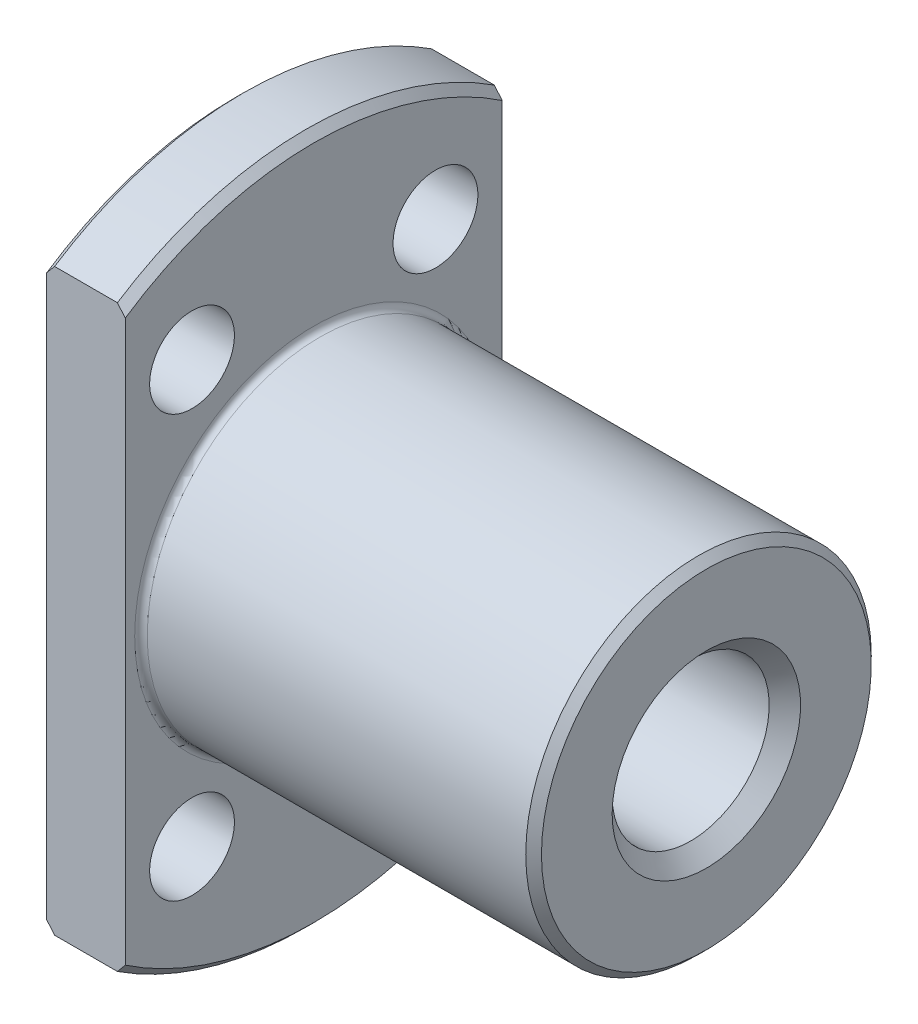
from build123d import *

# Parameters (mm, degrees)
SKETCH3_W               = 48
SKETCH3_H               = 132
SKETCH3_W_2             = 24
SKETCH3_H_2             = 88
CUT_EXTRUDE1_DEPTH      = 7.5
CUT_EXTRUDE1_DEPTH_BACK = 7.5
SKETCH4_R               = 2.7
CUT_EXTRUDE2_DEPTH      = 6
SKETCH5_R               = 2.7
CUT_EXTRUDE3_DEPTH      = 6
SKETCH6_R               = 2.7
CUT_EXTRUDE4_DEPTH      = 6
SKETCH7_R               = 2.7
CUT_EXTRUDE5_DEPTH      = 6


with BuildPart() as part:
    # Sketch1 → Revolve1 (revolve)
    with BuildSketch(Plane.XY):
        with BuildLine():
            Line((0, 0), (0, 21.5))
            Line((0, 21.5), (0.5, 22))
            Line((0.5, 22), (4.5, 22))
            Line((4.5, 22), (5, 21.5))
            Line((5, 21.5), (5, 11.4))
            ThreePointArc((5, 11.4), (5.117157288, 11.117157288), (5.4, 11))
            Line((5.4, 11), (29.5, 11))
            Line((29.5, 11), (30, 10.5))
            Line((30, 10.5), (30, 0))
            Line((30, 0), (0, 0))
        make_face()
    revolve(axis=Axis((30, 0, 0), (-1, 0, 0)))

    # Sketch2 → Cut-Revolve1 (revolve, cut)
    with BuildSketch(Plane.XY):
        Polygon((0, 0), (0, 6), (1, 5), (29, 5), (30, 6), (30, 0), align=None)
    revolve(axis=Axis((30, 0, 0), (-1, 0, 0)), mode=Mode.SUBTRACT)

    # Sketch3 → Cut-Extrude1 (cut, two sides)
    with BuildSketch(Plane(origin=(0, 0, 0), x_dir=(0, 0, -1), z_dir=(1, 0, 0))) as cut_extrude1_sk:
        Rectangle(SKETCH3_W, SKETCH3_H)
        Rectangle(SKETCH3_W_2, SKETCH3_H_2, mode=Mode.SUBTRACT)
    extrude(amount=CUT_EXTRUDE1_DEPTH, mode=Mode.SUBTRACT)
    extrude(cut_extrude1_sk.sketch, amount=-CUT_EXTRUDE1_DEPTH_BACK, mode=Mode.SUBTRACT)

    # Sketch4 → Cut-Extrude2 (cut)
    with BuildSketch(Plane(origin=(-0.5, 0, 0), x_dir=(0, 0, -1), z_dir=(1, 0, 0))):
        with Locations((-7.75, 13.423393759)):
            Circle(SKETCH4_R)
    extrude(amount=CUT_EXTRUDE2_DEPTH, mode=Mode.SUBTRACT)

    # Sketch5 → Cut-Extrude3 (cut)
    with BuildSketch(Plane(origin=(-0.5, 0, 0), x_dir=(0, 0, -1), z_dir=(1, 0, 0))):
        with Locations((-7.75, -13.423393759)):
            Circle(SKETCH5_R)
    extrude(amount=CUT_EXTRUDE3_DEPTH, mode=Mode.SUBTRACT)

    # Sketch6 → Cut-Extrude4 (cut)
    with BuildSketch(Plane(origin=(-0.5, 0, 0), x_dir=(0, 0, -1), z_dir=(1, 0, 0))):
        with Locations((7.75, -13.423393759)):
            Circle(SKETCH6_R)
    extrude(amount=CUT_EXTRUDE4_DEPTH, mode=Mode.SUBTRACT)

    # Sketch7 → Cut-Extrude5 (cut)
    with BuildSketch(Plane(origin=(-0.5, 0, 0), x_dir=(0, 0, -1), z_dir=(1, 0, 0))):
        with Locations((7.75, 13.423393759)):
            Circle(SKETCH7_R)
    extrude(amount=CUT_EXTRUDE5_DEPTH, mode=Mode.SUBTRACT)


solid = part.part
